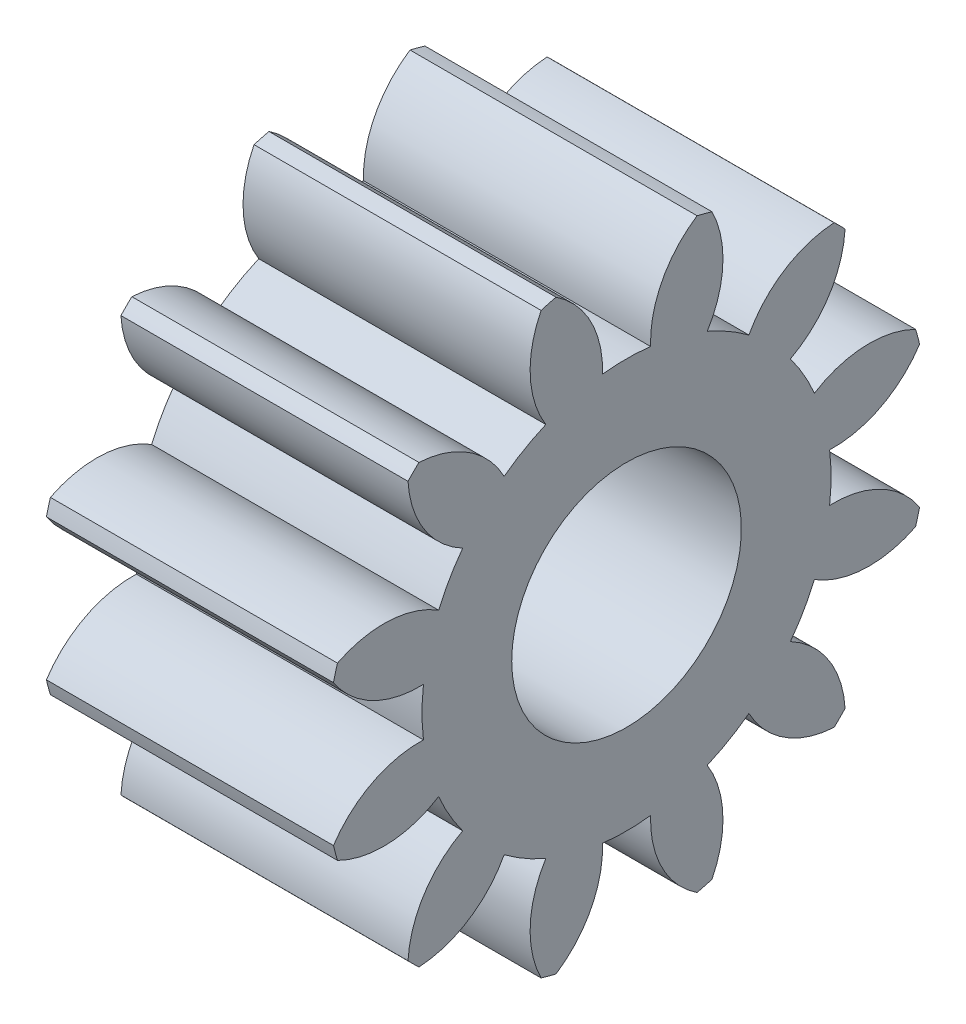
from build123d import *

# Parameters (mm, degrees)
BASPROSKE_W     = 10
BASPROSKE_H     = 10.5
TOOTHCUT_DEPTH  = 18.90251379
TEETHCUTS_COUNT = 12
TEETHCUTS_ANGLE = 330
BORSKE_R        = 4
BORE_DEPTH      = 50.0000508


with BuildPart() as part:
    # BasProSke → Base-Revolve (revolve)
    with BuildSketch(Plane(origin=(0, 0, 0), x_dir=(1, 0, 0), z_dir=(0, 1, 0)), mode=Mode.PRIVATE) as base_revolve_sk:
        with Locations((5, 5.25)):
            Rectangle(BASPROSKE_W, BASPROSKE_H)
    revolve(base_revolve_sk.sketch.rotate(Axis((-10, 0, 0), (1, 0, 0)), 180), axis=Axis((-10, 0, 0), (1, 0, 0)))

    # TooCutSke → ToothCut (cut, through all)
    with BuildSketch(Plane(origin=(0, 0, 0), x_dir=(0, 0, -1), z_dir=(1, 0, 0))):
        with BuildLine():
            ThreePointArc((0.837751456, 7.074570552), (0, 7.124), (-0.837751456, 7.074570552))
            ThreePointArc((-0.837751456, 7.074570552), (-1.245380016, 8.868946541), (-2.486473743, 10.227487154))
            ThreePointArc((-2.486473743, 10.227487154), (0, 10.5254), (2.486473743, 10.227487154))
            ThreePointArc((2.486473743, 10.227487154), (1.245380016, 8.868946541), (0.837751456, 7.074570552))
        make_face()
    toothcut = extrude(amount=TOOTHCUT_DEPTH, mode=Mode.SUBTRACT)

    # TeethCuts: ToothCut ×12 about axis
    teethcuts_axis = Axis((-10, 0, 0), (1, 0, 0))
    for i in range(1, TEETHCUTS_COUNT):
        add(toothcut.rotate(teethcuts_axis, i * TEETHCUTS_ANGLE / (TEETHCUTS_COUNT - 1)), mode=Mode.SUBTRACT)

    # BorSke → Bore (cut, symmetric)
    with BuildSketch(Plane(origin=(0, 0, 0), x_dir=(0, 0, -1), z_dir=(1, 0, 0))):
        with Locations(Location((0, 0, 0), (0, 0, 180))):
            Circle(BORSKE_R)
    extrude(amount=BORE_DEPTH, both=True, mode=Mode.SUBTRACT)


solid = part.part
